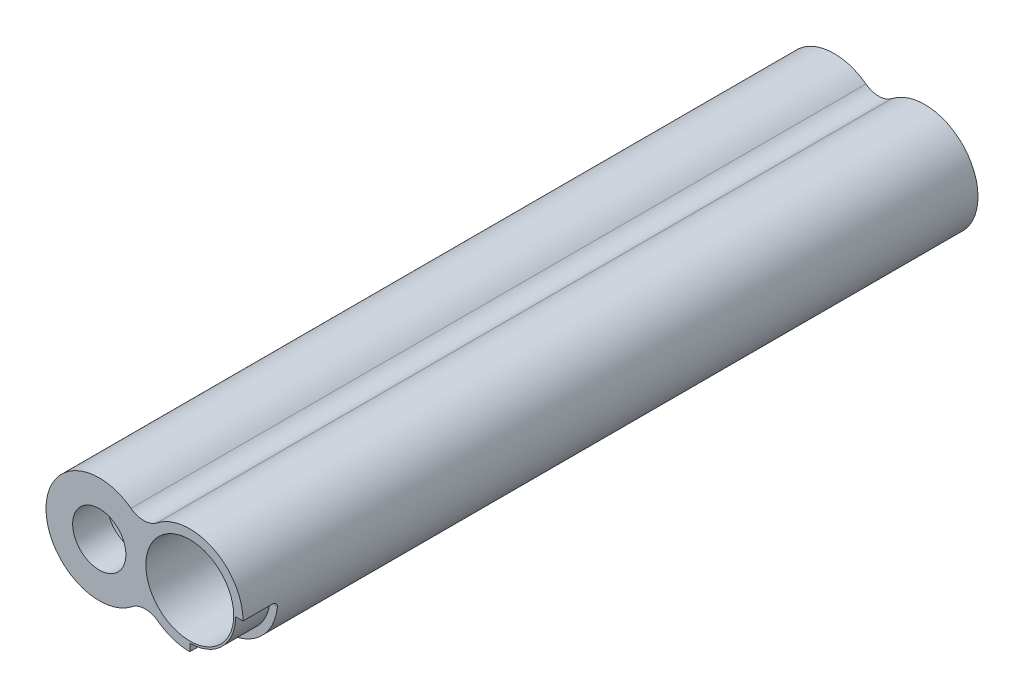
from build123d import *

# Parameters (mm, degrees)
BOSS_EXTRUDE1_DEPTH = 34.5
SKETCH2_R           = 4.125
CUT_EXTRUDE1_DEPTH  = 34.5
SKETCH3_R           = 4.125
SKETCH3_R_2         = 2.5
BOSS_EXTRUDE2_DEPTH = 3.25
SKETCH5_R           = 4.125
SKETCH5_R_2         = 2.5
BOSS_EXTRUDE4_DEPTH = 3.25
CUT_EXTRUDE3_DEPTH  = 3.25
FILLET1_R           = 0.5
CUT_EXTRUDE4_DEPTH  = 3.25
FILLET2_R           = 0.5


with BuildPart() as part:
    # Sketch1 → Boss-Extrude1 (new body, symmetric)
    with BuildSketch(Plane.XY):
        with BuildLine():
            ThreePointArc((2.986131566, 4.010363858), (-4.999610571, -0.062403009), (3.085297006, -3.934582873))
            ThreePointArc((3.085297006, -3.934582873), (4.294454604, -3.508571794), (5.513868434, -3.904270479))
            ThreePointArc((5.513868434, -3.904270479), (13.499610571, 0.168496387), (5.414702994, 4.040676252))
            ThreePointArc((5.414702994, 4.040676252), (4.205545396, 3.614665172), (2.986131566, 4.010363858))
        make_face()
    extrude(amount=BOSS_EXTRUDE1_DEPTH, both=True)

    # Sketch2 → Cut-Extrude1 (cut, symmetric)
    with BuildSketch(Plane.XY):
        Circle(SKETCH2_R)
        with Locations((8.5, 0.106093378)):
            Circle(SKETCH2_R)
    extrude(amount=CUT_EXTRUDE1_DEPTH, both=True, mode=Mode.SUBTRACT)

    # Sketch3 → Boss-Extrude2 (add)
    with BuildSketch(Plane.XY.offset(34.5)):
        Circle(SKETCH3_R)
        Circle(SKETCH3_R_2, mode=Mode.SUBTRACT)
    extrude(amount=-BOSS_EXTRUDE2_DEPTH)

    # Sketch5 → Boss-Extrude4 (add)
    with BuildSketch(Plane(origin=(0, 0, -34.5), x_dir=(-1, 0, 0), z_dir=(0, 0, -1))):
        with Locations((-8.5, 0.106093378)):
            Circle(SKETCH5_R)
        with Locations((-8.5, 0.106093378)):
            Circle(SKETCH5_R_2, mode=Mode.SUBTRACT)
    extrude(amount=-BOSS_EXTRUDE4_DEPTH)

    # Sketch6 → Cut-Extrude3 (cut)
    with BuildSketch(Plane(origin=(0, 0, -34.5), x_dir=(-1, 0, 0), z_dir=(0, 0, -1))):
        with BuildLine():
            Line((4.299610571, -0.062403009), (4.999610571, -0.062403009))
            ThreePointArc((4.999610571, -0.062403009), (3.513401838, -3.557528288), (0, -5))
            Line((0, -5), (0, -4.300063395))
            ThreePointArc((0, -4.300063395), (3.01846056, -3.062587313), (4.299610571, -0.062403009))
        make_face()
    extrude(amount=-CUT_EXTRUDE3_DEPTH, mode=Mode.SUBTRACT)

    # Fillet1
    fillet1_edges = [part.edges().sort_by_distance(p)[0] for p in [
        (0, -4.650031697, -31.25),
        (-4.649610571, -0.062403009, -31.25),
    ]]
    fillet(fillet1_edges, radius=FILLET1_R)

    # Sketch7 → Cut-Extrude4 (cut)
    with BuildSketch(Plane.XY.offset(34.5)):
        with BuildLine():
            Line((13.5, 0.106093378), (12.8, 0.106093378))
            ThreePointArc((12.8, 0.106093378), (11.540559159, -2.934465781), (8.5, -4.193906622))
            Line((8.5, -4.193906622), (8.5, -4.893906622))
            ThreePointArc((8.5, -4.893906622), (12.035533906, -3.429440528), (13.5, 0.106093378))
        make_face()
    extrude(amount=-CUT_EXTRUDE4_DEPTH, mode=Mode.SUBTRACT)

    # Fillet2
    fillet2_edges = [part.edges().sort_by_distance(p)[0] for p in [
        (8.5, -4.543906622, 31.25),
        (13.15, 0.106093378, 31.25),
    ]]
    fillet(fillet2_edges, radius=FILLET2_R)


solid = part.part
